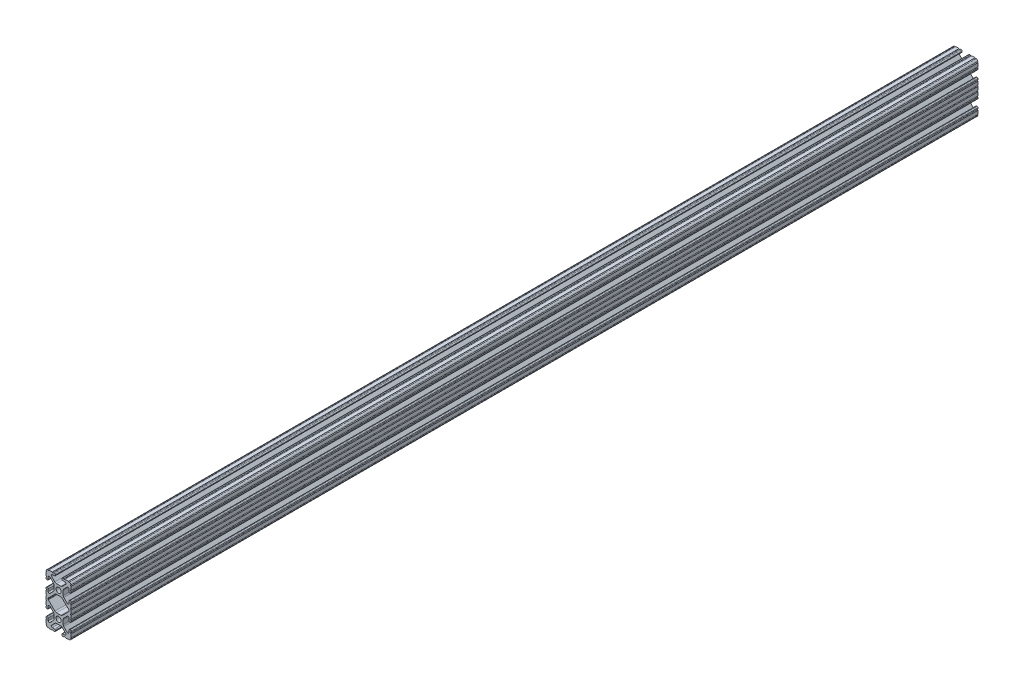
from build123d import *

# Parameters (mm, degrees)
BOSS_EXTRUDE1_DEPTH     = 457.2
SKETCH5_R               = 0.55245
CUT_EXTRUDE1_DEPTH      = 458.2
CUT_EXTRUDE1_DEPTH_BACK = 458.2
BOSS_EXTRUDE2_DEPTH     = 457.2
CUT_EXTRUDE2_DEPTH      = 458.2
CUT_EXTRUDE2_DEPTH_BACK = 458.2


with BuildPart() as part:
    # Sketch4 → Boss-Extrude1 (new body, symmetric)
    with BuildSketch(Plane.XY):
        with BuildLine():
            Line((4.190365, -25.4), (10.11729625, -25.4))
            ThreePointArc((10.11729625, -25.4), (11.943543585, -24.643543585), (12.7, -22.81729625))
            Line((12.7, -22.81729625), (12.7, -16.890365))
            ThreePointArc((12.7, -16.890365), (12.42492494, -16.22627506), (11.760835, -15.9512))
            Line((11.760835, -15.9512), (11.429365, -15.9512))
            ThreePointArc((11.429365, -15.9512), (10.76527506, -16.22627506), (10.4902, -16.890365))
            Line((10.4902, -16.890365), (10.4902, -19.048478019))
            ThreePointArc((10.4902, -19.048478019), (9.830707141, -20.035478831), (8.666460301, -19.803895736))
            Line((8.666460301, -19.803895736), (5.299899128, -16.437334563))
            ThreePointArc((5.299899128, -16.437334563), (4.817571085, -15.715479634), (4.6482, -14.86399369))
            Line((4.6482, -14.86399369), (4.6482, -12.7))
            Line((4.6482, -12.7), (2.6035, -12.7))
            ThreePointArc((2.6035, -12.7), (1.840952505, -14.540952505), (0, -15.3035))
            Line((0, -15.3035), (0, -17.3482))
            Line((0, -17.3482), (2.16399369, -17.3482))
            ThreePointArc((2.16399369, -17.3482), (3.015479634, -17.517571085), (3.737334563, -17.999899128))
            Line((3.737334563, -17.999899128), (7.103895736, -21.366460301))
            ThreePointArc((7.103895736, -21.366460301), (7.335478831, -22.530707141), (6.348478019, -23.1902))
            Line((6.348478019, -23.1902), (4.190365, -23.1902))
            ThreePointArc((4.190365, -23.1902), (3.52627506, -23.46527506), (3.2512, -24.129365))
            Line((3.2512, -24.129365), (3.2512, -24.460835))
            ThreePointArc((3.2512, -24.460835), (3.52627506, -25.12492494), (4.190365, -25.4))
        make_face()
    extrude(amount=BOSS_EXTRUDE1_DEPTH, both=True)

    # Sketch5 → Cut-Extrude1 (cut, two sides)
    with BuildSketch(Plane.XY) as cut_extrude1_sk:
        with Locations((10.356153152, -25.4)):
            Circle(SKETCH5_R)
        with Locations((5.796028019, -25.4)):
            Circle(SKETCH5_R)
        with Locations((12.7, -23.056153152)):
            Circle(SKETCH5_R)
        with Locations((12.7, -18.496028019)):
            Circle(SKETCH5_R)
    extrude(amount=CUT_EXTRUDE1_DEPTH, mode=Mode.SUBTRACT)
    extrude(cut_extrude1_sk.sketch, amount=-CUT_EXTRUDE1_DEPTH_BACK, mode=Mode.SUBTRACT)

    # Mirror1: part across plane


with BuildPart() as part_1:
    add(part.part)
    add(part.part.mirror(Plane(origin=(4.6482, -12.7, 457.2), x_dir=(0, 0, 1), z_dir=(0, -1, 0))))

    # Sketch6 → Boss-Extrude2 (add, symmetric)
    with BuildSketch(Plane.XY):
        with BuildLine():
            Line((12.7, -1.791396848), (12.7, 0))
            Line((12.7, 0), (9.803703152, 0))
            Line((9.803703152, 0), (9.803703152, -2.343846848))
            Line((9.803703152, -2.343846848), (12.14755, -2.343846848))
            ThreePointArc((12.14755, -2.343846848), (12.309358859, -1.953205706), (12.7, -1.791396848))
        make_face()
    extrude(amount=BOSS_EXTRUDE2_DEPTH, both=True)

    # Sketch7 → Cut-Extrude2 (cut, two sides)
    with BuildSketch(Plane.XY) as cut_extrude2_sk:
        with BuildLine():
            Line((5.420615149, -5.716820286), (10.328391141, -0.809044294))
            ThreePointArc((10.328391141, -0.809044294), (10.448147248, -0.629816615), (10.4902, -0.418403152))
            Line((10.4902, -0.418403152), (10.4902, 0))
            Line((10.4902, 0), (0, 0))
            Line((0, 0), (5.420615149, -5.716820286))
        make_face()
    extrude(amount=CUT_EXTRUDE2_DEPTH, mode=Mode.SUBTRACT)
    extrude(cut_extrude2_sk.sketch, amount=-CUT_EXTRUDE2_DEPTH_BACK, mode=Mode.SUBTRACT)

    # Mirror2: part across plane


with BuildPart() as part_2:
    add(part_1.part)
    add(part_1.part.mirror(Plane.ZX))

    # Mirror3: part across plane


with BuildPart() as part_3:
    add(part_2.part)
    add(part_2.part.mirror(Plane(origin=(0, 0, 0), x_dir=(0, 0, 1), z_dir=(1, 0, 0))))


solid = part_3.part
